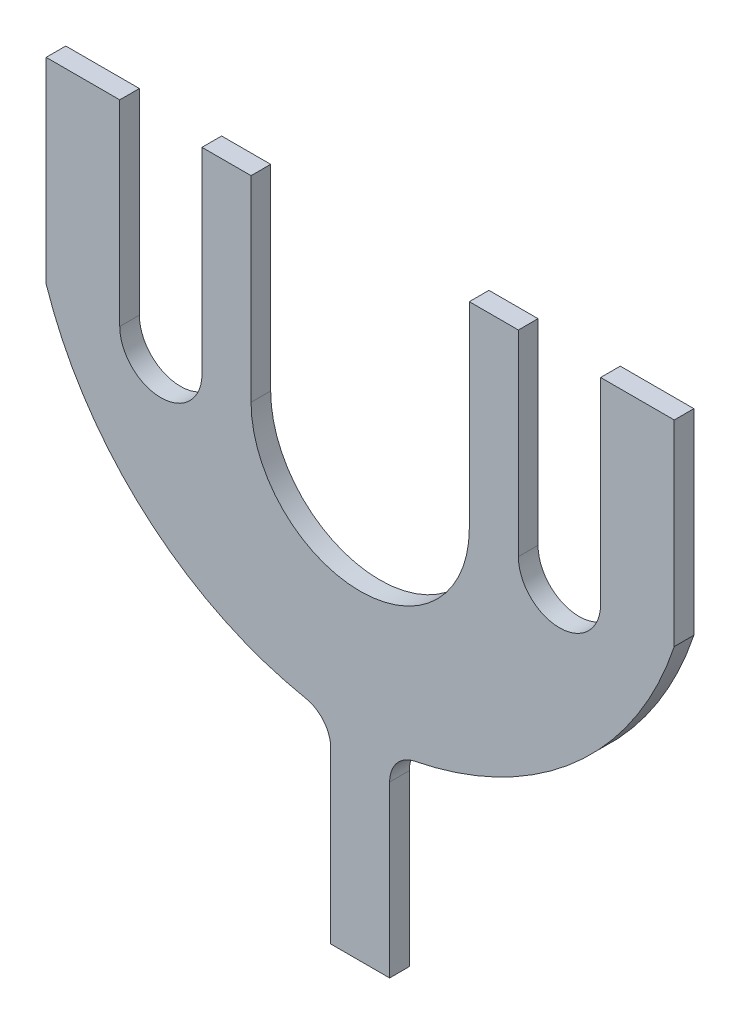
from build123d import *

# Parameters (mm, degrees)
BOSS_EXTRUDE2_DEPTH = 1


with BuildPart() as part:
    # Sketch2 → Boss-Extrude2 (new body)
    with BuildSketch(Plane.XY):
        with BuildLine():
            Line((-21, 21.487770019), (-17.25, 21.487770019))
            Line((-17.25, 21.487770019), (-17.25, 11.487770019))
            ThreePointArc((-17.25, 11.487770019), (-15.155, 9.392770019), (-13.06, 11.487770019))
            Line((-13.06, 11.487770019), (-13.06, 21.487770019))
            Line((-13.06, 21.487770019), (-10.56, 21.487770019))
            Line((-10.56, 21.487770019), (-10.56, 11.487770019))
            ThreePointArc((-10.56, 11.487770019), (-5, 5.927770019), (0.56, 11.487770019))
            Line((0.56, 11.487770019), (0.56, 21.487770019))
            Line((0.56, 21.487770019), (3.06, 21.487770019))
            Line((3.06, 21.487770019), (3.06, 11.487770019))
            ThreePointArc((3.06, 11.487770019), (5.155, 9.392770019), (7.25, 11.487770019))
            Line((7.25, 11.487770019), (7.25, 21.487770019))
            Line((7.25, 21.487770019), (11, 21.487770019))
            Line((11, 21.487770019), (11, 11.487770019))
            ThreePointArc((11, 11.487770019), (5.966787544, 3.86706946), (-2.220289758, -0.18016044))
            ThreePointArc((-2.220289758, -0.18016044), (-3.139034242, -0.72968283), (-3.5, -1.737536988))
            Line((-3.5, -1.737536988), (-3.5, -10.384166662))
            Line((-3.5, -10.384166662), (-6.5, -10.384166662))
            Line((-6.5, -10.384166662), (-6.5, -1.737536988))
            ThreePointArc((-6.5, -1.737536988), (-6.860965758, -0.72968283), (-7.779710242, -0.18016044))
            ThreePointArc((-7.779710242, -0.18016044), (-15.966787544, 3.86706946), (-21, 11.487770019))
            Line((-21, 11.487770019), (-21, 21.487770019))
        make_face()
    extrude(amount=BOSS_EXTRUDE2_DEPTH)


solid = part.part
